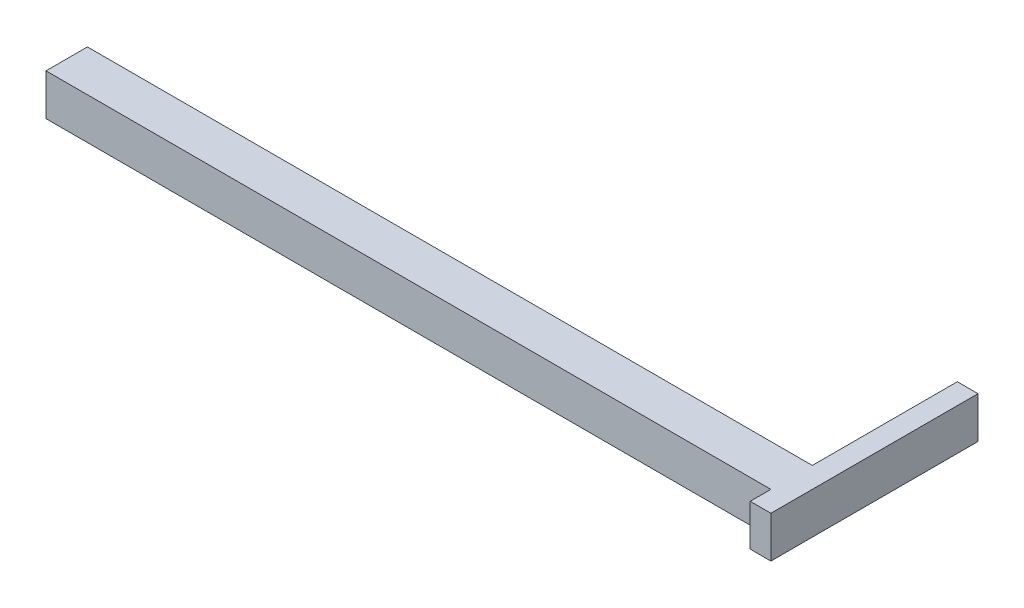
from build123d import *

# Parameters (mm, degrees)
CROQUIS1_W              = 3500
CROQUIS1_H              = 200
SALIENTE_EXTRUIR1_DEPTH = 200
SALIENTE_EXTRUIR2_DEPTH = 100


with BuildPart() as part:
    # Croquis1 → Saliente-Extruir1 (new body)
    with BuildSketch(Plane.XY):
        Rectangle(CROQUIS1_W, CROQUIS1_H)
    extrude(amount=SALIENTE_EXTRUIR1_DEPTH)

    # Croquis2 → Saliente-Extruir2 (add)
    with BuildSketch(Plane(origin=(1750, 0, 0), x_dir=(0, 0, -1), z_dir=(1, 0, 0))):
        Polygon((0, 100), (-300, 100), (-300, -100), (0, -100), (700, -100), (700, 100), align=None)
    extrude(amount=SALIENTE_EXTRUIR2_DEPTH)


solid = part.part
